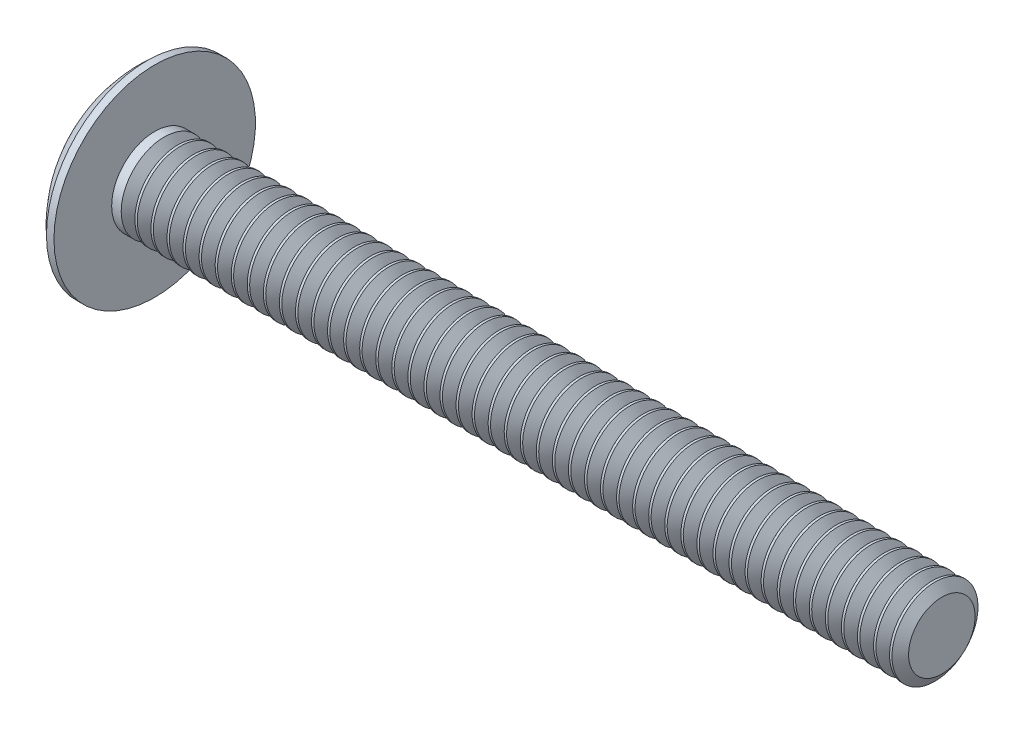
from build123d import *

# Parameters (mm, degrees)
SKETCH3_W         = 1.0414
SKETCH3_H         = 5.461
SKETCH4_W         = 0.5207
SKETCH4_H         = 0.5207
CIRPATTERN1_COUNT = 2
CIRPATTERN1_ANGLE = 90
THDSCHPAT_COUNT   = 49
THDSCHPAT_PITCH   = 0.77724


with BuildPart() as part:
    # BodySke → Base-Revolve (revolve)
    with BuildSketch(Plane.XY):
        with BuildLine():
            Line((2.5908, 2.0828), (2.5908, 4.8768))
            Line((2.5908, 4.8768), (2.227861807, 4.8768))
            ThreePointArc((2.227861807, 4.8768), (0.5833374, 2.680790297), (0, 0))
            Line((0, 0), (40.6908, 0))
            Line((40.6908, 0), (40.6908, 2.0828))
            Line((40.6908, 2.0828), (2.5908, 2.0828))
        make_face()
    revolve(axis=Axis((-25.4, 0, 0), (1, 0, 0)))

    # Sketch3 → Cross section 0
    with BuildSketch(Plane(origin=(0, 0, 0), x_dir=(0, 0, -1), z_dir=(1, 0, 0))):
        Rectangle(SKETCH3_W, SKETCH3_H)
    # Sketch4 → Cross section 1
    with BuildSketch(Plane(origin=(3.0734, 0, 0), x_dir=(0, 0, -1), z_dir=(1, 0, 0))):
        Rectangle(SKETCH4_W, SKETCH4_H)
    cross = loft(mode=Mode.SUBTRACT)

    # CirPattern1: Cross ×2 about axis
    cirpattern1_axis = Axis((0, 0, 0), (1, 0, 0))
    for i in range(1, CIRPATTERN1_COUNT):
        add(cross.rotate(cirpattern1_axis, i * CIRPATTERN1_ANGLE / (CIRPATTERN1_COUNT - 1)), mode=Mode.SUBTRACT)

    # ThdSchSke → ThreadSchematic (revolve, cut)
    with BuildSketch(Plane.XY):
        Polygon((3.38328, -1.61036), (3.052473951, -2.0828), (3.052473951, -2.6035), (3.714086049, -2.6035), (3.714086049, -2.0828), align=None)
    threadschematic = revolve(axis=Axis((-3.175, 0, 0), (1, 0, 0)), mode=Mode.SUBTRACT)

    # ThdSchPat: ThreadSchematic ×49
    with Locations(*[(i * THDSCHPAT_PITCH, 0, 0) for i in range(1, THDSCHPAT_COUNT)]):
        add(threadschematic, mode=Mode.SUBTRACT)


solid = part.part
